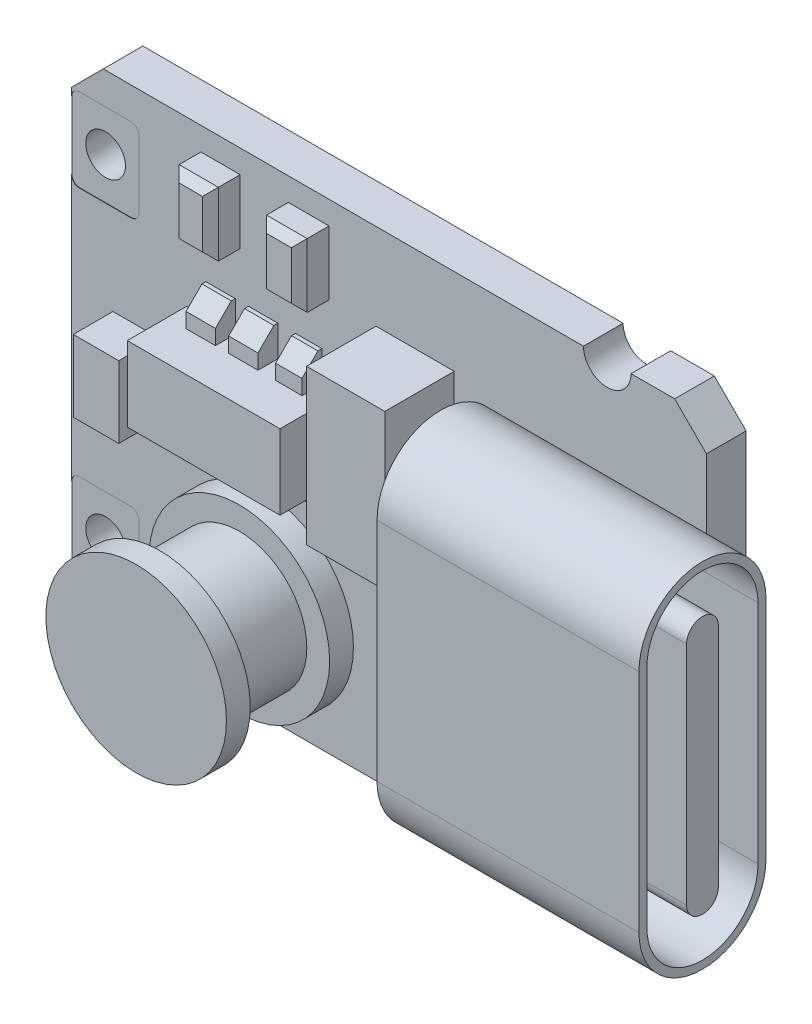
from build123d import *

# Parameters (mm, degrees)
BOSS_EXTRU_1_DEPTH      = 1
ESQUISSE2_R             = 0.5
ENL_V_MAT_EXTRU_1_DEPTH = 10
ENL_V_MAT_EXTRU_2_DEPTH = 0.01
ENL_V_START             = -1
ENL_V_MAT_EXTRU_3_DEPTH = 0.01
BOSS_EXTRU_2_DEPTH      = 1.5
BOSS_EXTRU_2_DEPTH_BACK = 5.1
ESQUISSE5_R             = 2.275332805
BOSS_EXTRU_3_DEPTH      = 3.2
ENL_V_START_2           = -0.6
ESQUISSE6_R             = 2.275332805
ESQUISSE6_R_2           = 1.7
ENL_V_MAT_EXTRU_4_DEPTH = 2
ESQUISSE7_W             = 1.97090018
ESQUISSE7_H             = 3.898474417
ESQUISSE7_W_2           = 0.989857895
ESQUISSE7_H_2           = 1.612554693
ESQUISSE7_W_3           = 1.027355852
ESQUISSE7_W_4           = 1.146705559
ESQUISSE7_H_3           = 1.806710228
BOSS_EXTRU_4_DEPTH      = 1.5
ESQUISSE8_W             = 1.25807389
ESQUISSE8_H             = 0.666039119
ESQUISSE8_W_2           = 0.69364074
ESQUISSE8_H_2           = 1.255273727
BOSS_EXTRU_5_DEPTH      = 0.5
ESQUISSE9_W             = 3.84822602
ESQUISSE9_H             = 0.777045638
ENL_V_MAT_EXTRU_5_DEPTH = 1
CHANFREIN1_SIZE         = 0.4
ESQUISSE10_W            = 3.228737269
ESQUISSE10_H            = 1.612554693
ENL_V_MAT_EXTRU_6_DEPTH = 0.75
ESQUISSE11_W            = 1.213675147
ESQUISSE11_H            = 1.927537991
ENL_V_MAT_EXTRU_7_DEPTH = 0.5
ESQUISSE12_W            = 1.97090018
ESQUISSE12_H            = 3.898474417
BOSS_EXTRU_6_DEPTH      = 0.25
CHANFREIN2_SIZE         = 0.2
ENL_V_MAT_EXTRU_8_DEPTH = 6.25


with BuildPart() as part:
    # Esquisse1 → Boss.-Extru.1 (new body)
    with BuildSketch(Plane.XY):
        with BuildLine():
            Line((0, 11.3), (0.8, 12.1))
            Line((0.8, 12.1), (12.9, 12.1))
            ThreePointArc((12.9, 12.1), (13.5, 11.5), (14.1, 12.1))
            Line((14.1, 12.1), (15.2, 12.1))
            Line((15.2, 12.1), (16, 11.3))
            Line((16, 11.3), (16, 0.8))
            Line((16, 0.8), (15.2, 0))
            Line((15.2, 0), (14.1, 0))
            ThreePointArc((14.1, 0), (13.5, 0.6), (12.9, 0))
            Line((12.9, 0), (0.8, 0))
            Line((0.8, 0), (0, 0.8))
            Line((0, 0.8), (0, 11.3))
        make_face()
    extrude(amount=BOSS_EXTRU_1_DEPTH)

    # Esquisse2 → Enl_v. mat.-Extru.1 (cut)
    with BuildSketch(Plane.XY.offset(1)):
        with Locations((0.85, 10.25)):
            Circle(ESQUISSE2_R)
        with Locations((0.85, 1.85)):
            Circle(ESQUISSE2_R)
    extrude(amount=-ENL_V_MAT_EXTRU_1_DEPTH, mode=Mode.SUBTRACT)

    # Esquisse3 → Enl_v. mat.-Extru.2 (cut)
    with BuildSketch(Plane.XY.offset(1)):
        with BuildLine():
            Line((1.5, 9.2), (0.2, 9.2))
            ThreePointArc((0.2, 9.2), (0.058578644, 9.258578644), (0, 9.4))
            Line((0, 9.4), (0, 11.1))
            ThreePointArc((0, 11.1), (0.058578644, 11.241421356), (0.2, 11.3))
            Line((0.2, 11.3), (1.5, 11.3))
            ThreePointArc((1.5, 11.3), (1.641421356, 11.241421356), (1.7, 11.1))
            Line((1.7, 11.1), (1.7, 9.4))
            ThreePointArc((1.7, 9.4), (1.641421356, 9.258578644), (1.5, 9.2))
        make_face()
        with BuildLine():
            Line((1.5, 2.9), (0.2, 2.9))
            ThreePointArc((0.2, 2.9), (0.058578644, 2.841421356), (0, 2.7))
            Line((0, 2.7), (0, 1))
            ThreePointArc((0, 1), (0.058578644, 0.858578644), (0.2, 0.8))
            Line((0.2, 0.8), (1.5, 0.8))
            ThreePointArc((1.5, 0.8), (1.641421356, 0.858578644), (1.7, 1))
            Line((1.7, 1), (1.7, 2.7))
            ThreePointArc((1.7, 2.7), (1.641421356, 2.841421356), (1.5, 2.9))
        make_face()
    extrude(amount=-ENL_V_MAT_EXTRU_2_DEPTH, mode=Mode.SUBTRACT)

    # Esquisse3_2 → Enl_v. mat.-Extru.3 (cut)
    with BuildSketch(Plane.XY.offset(1).offset(ENL_V_START)):
        with BuildLine():
            Line((1.5, 9.2), (0.2, 9.2))
            ThreePointArc((0.2, 9.2), (0.058578644, 9.258578644), (0, 9.4))
            Line((0, 9.4), (0, 11.1))
            ThreePointArc((0, 11.1), (0.058578644, 11.241421356), (0.2, 11.3))
            Line((0.2, 11.3), (1.5, 11.3))
            ThreePointArc((1.5, 11.3), (1.641421356, 11.241421356), (1.7, 11.1))
            Line((1.7, 11.1), (1.7, 9.4))
            ThreePointArc((1.7, 9.4), (1.641421356, 9.258578644), (1.5, 9.2))
        make_face()
        with BuildLine():
            Line((1.5, 2.9), (0.2, 2.9))
            ThreePointArc((0.2, 2.9), (0.058578644, 2.841421356), (0, 2.7))
            Line((0, 2.7), (0, 1))
            ThreePointArc((0, 1), (0.058578644, 0.858578644), (0.2, 0.8))
            Line((0.2, 0.8), (1.5, 0.8))
            ThreePointArc((1.5, 0.8), (1.641421356, 0.858578644), (1.7, 1))
            Line((1.7, 1), (1.7, 2.7))
            ThreePointArc((1.7, 2.7), (1.641421356, 2.841421356), (1.5, 2.9))
        make_face()
    extrude(amount=ENL_V_MAT_EXTRU_3_DEPTH, mode=Mode.SUBTRACT)

    # Esquisse4 → Boss.-Extru.2 (add, two sides)
    with BuildSketch(Plane(origin=(16, 0, 0), x_dir=(0, 0, -1), z_dir=(1, 0, 0))) as boss_extru_2_sk:
        with BuildLine():
            Line((-4.2, 3.2), (-4.2, 8.9))
            ThreePointArc((-4.2, 8.9), (-2.6, 10.5), (-1, 8.9))
            Line((-1, 8.9), (-1, 3.2))
            ThreePointArc((-1, 3.2), (-2.6, 1.6), (-4.2, 3.2))
        make_face()
    extrude(amount=BOSS_EXTRU_2_DEPTH)
    extrude(boss_extru_2_sk.sketch, amount=-BOSS_EXTRU_2_DEPTH_BACK)

    # Esquisse5 → Boss.-Extru.3 (add)
    with BuildSketch(Plane.XY.offset(1)):
        with Locations((4.830231602, 2.627298973)):
            Circle(ESQUISSE5_R)
    extrude(amount=BOSS_EXTRU_3_DEPTH)

    # Esquisse6 → Enl_v. mat.-Extru.4 (cut)
    with BuildSketch(Plane.XY.offset(4.2).offset(ENL_V_START_2)):
        with Locations((4.830231602, 2.627298973)):
            Circle(ESQUISSE6_R)
        with Locations((4.830231602, 2.627298973)):
            Circle(ESQUISSE6_R_2, mode=Mode.SUBTRACT)
    extrude(amount=-ENL_V_MAT_EXTRU_4_DEPTH, mode=Mode.SUBTRACT)

    # Esquisse7 → Boss.-Extru.4 (add)
    with BuildSketch(Plane.XY.offset(1)):
        Polygon((4.12719031, 7.97411301), (4.460209869, 7.97411301), (4.460209869, 8.751158648), (5.200253335, 8.751158648), (5.200253335, 7.97411301), (5.644279414, 7.97411301), (5.644279414, 8.751158648), (6.310318533, 8.751158648), (6.310318533, 7.97411301), (6.754344612, 7.97411301), (6.754344612, 6.087002173), (6.310318533, 6.087002173), (6.310318533, 5.309956535), (5.644279414, 5.309956535), (5.644279414, 6.087002173), (5.200253335, 6.087002173), (5.200253335, 5.309956535), (4.460209869, 5.309956535), (4.460209869, 6.087002173), (4.12719031, 6.087002173), (4.12719031, 5.309956535), (3.387146845, 5.309956535), (3.387146845, 6.087002173), (2.906118592, 6.087002173), (2.906118592, 7.97411301), (3.387146845, 7.97411301), (3.387146845, 8.751158648), (4.12719031, 8.751158648), align=None)
        with Locations((8.659747019, 7.97411301)):
            Rectangle(ESQUISSE7_W, ESQUISSE7_H)
        with Locations((3.757168577, 10.711710291)):
            Rectangle(ESQUISSE7_W_2, ESQUISSE7_H_2)
        with Locations((5.977298973, 10.711710291)):
            Rectangle(ESQUISSE7_W_3, ESQUISSE7_H_2)
        with Locations((1.618258193, 6.024875801)):
            Rectangle(ESQUISSE7_W_4, ESQUISSE7_H_3)
    extrude(amount=BOSS_EXTRU_4_DEPTH)

    # Esquisse8 → Boss.-Extru.5 (add)
    with BuildSketch(Plane.XY.offset(1)):
        with Locations((8.548950015, 5.217451102)):
            Rectangle(ESQUISSE8_W, ESQUISSE8_H)
        with Locations((10.079839929, 3.846970609)):
            Rectangle(ESQUISSE8_W_2, ESQUISSE8_H_2)
    extrude(amount=BOSS_EXTRU_5_DEPTH)

    # Esquisse9 → Enl_v. mat.-Extru.5 (cut)
    with BuildSketch(Plane.XY.offset(2.5)):
        with Locations((4.830231602, 8.362635829)):
            Rectangle(ESQUISSE9_W, ESQUISSE9_H)
        with Locations((4.830231602, 5.698479354)):
            Rectangle(ESQUISSE9_W, ESQUISSE9_H)
    extrude(amount=-ENL_V_MAT_EXTRU_5_DEPTH, mode=Mode.SUBTRACT)

    # Chanfrein1
    chanfrein1_edges = [part.edges().sort_by_distance(p)[0] for p in [
        (3.757168577, 5.309956535, 1.5),
        (4.830231602, 5.309956535, 1.5),
        (5.977298973, 5.309956535, 1.5),
        (5.977298973, 8.751158648, 1.5),
        (4.830231602, 8.751158648, 1.5),
        (3.757168577, 8.751158648, 1.5),
    ]]
    chamfer(chanfrein1_edges, length=CHANFREIN1_SIZE)

    # Esquisse10 → Enl_v. mat.-Extru.6 (cut)
    with BuildSketch(Plane.XY.offset(2.5)):
        with Locations((4.876608265, 10.711710291)):
            Rectangle(ESQUISSE10_W, ESQUISSE10_H)
    extrude(amount=-ENL_V_MAT_EXTRU_6_DEPTH, mode=Mode.SUBTRACT)

    # Esquisse11 → Enl_v. mat.-Extru.7 (cut)
    with BuildSketch(Plane.XY.offset(2.5)):
        with Locations((1.651742986, 6.085289683)):
            Rectangle(ESQUISSE11_W, ESQUISSE11_H)
    extrude(amount=-ENL_V_MAT_EXTRU_7_DEPTH, mode=Mode.SUBTRACT)

    # Esquisse12 → Boss.-Extru.6 (add)
    with BuildSketch(Plane.XY.offset(2.5)):
        with Locations((8.659747019, 7.97411301)):
            Rectangle(ESQUISSE12_W, ESQUISSE12_H)
    extrude(amount=BOSS_EXTRU_6_DEPTH)

    # Chanfrein2
    chanfrein2_edges = [part.edges().sort_by_distance(p)[0] for p in [
        (4.252097525, 10.71171029, 1.75),
        (5.463621047, 10.71171029, 1.75),
        (3.757168577, 9.905432944, 1.75),
        (5.977298973, 9.905432944, 1.75),
        (3.757168577, 11.517987637, 1.75),
        (5.977298973, 11.517987637, 1.75),
        (6.490976899, 10.71171029, 1.75),
        (3.26223963, 10.71171029, 1.75),
    ]]
    chamfer(chanfrein2_edges, length=CHANFREIN2_SIZE)

    # Esquisse13 → Enl_v. mat.-Extru.8 (cut)
    with BuildSketch(Plane(origin=(17.5, 0, 0), x_dir=(0, 0, -1), z_dir=(1, 0, 0))):
        with BuildLine():
            Line((-1.2, 3.2), (-1.2, 8.9))
            ThreePointArc((-1.2, 8.9), (-2.6, 10.3), (-4, 8.9))
            Line((-4, 8.9), (-4, 3.2))
            ThreePointArc((-4, 3.2), (-2.6, 1.8), (-1.2, 3.2))
        make_face()
        with BuildLine():
            Line((-2.2, 3.2), (-2.2, 8.9))
            ThreePointArc((-2.2, 8.9), (-2.6, 9.3), (-3, 8.9))
            Line((-3, 8.9), (-3, 3.2))
            ThreePointArc((-3, 3.2), (-2.6, 2.8), (-2.2, 3.2))
        make_face(mode=Mode.SUBTRACT)
    extrude(amount=-ENL_V_MAT_EXTRU_8_DEPTH, mode=Mode.SUBTRACT)


solid = part.part
